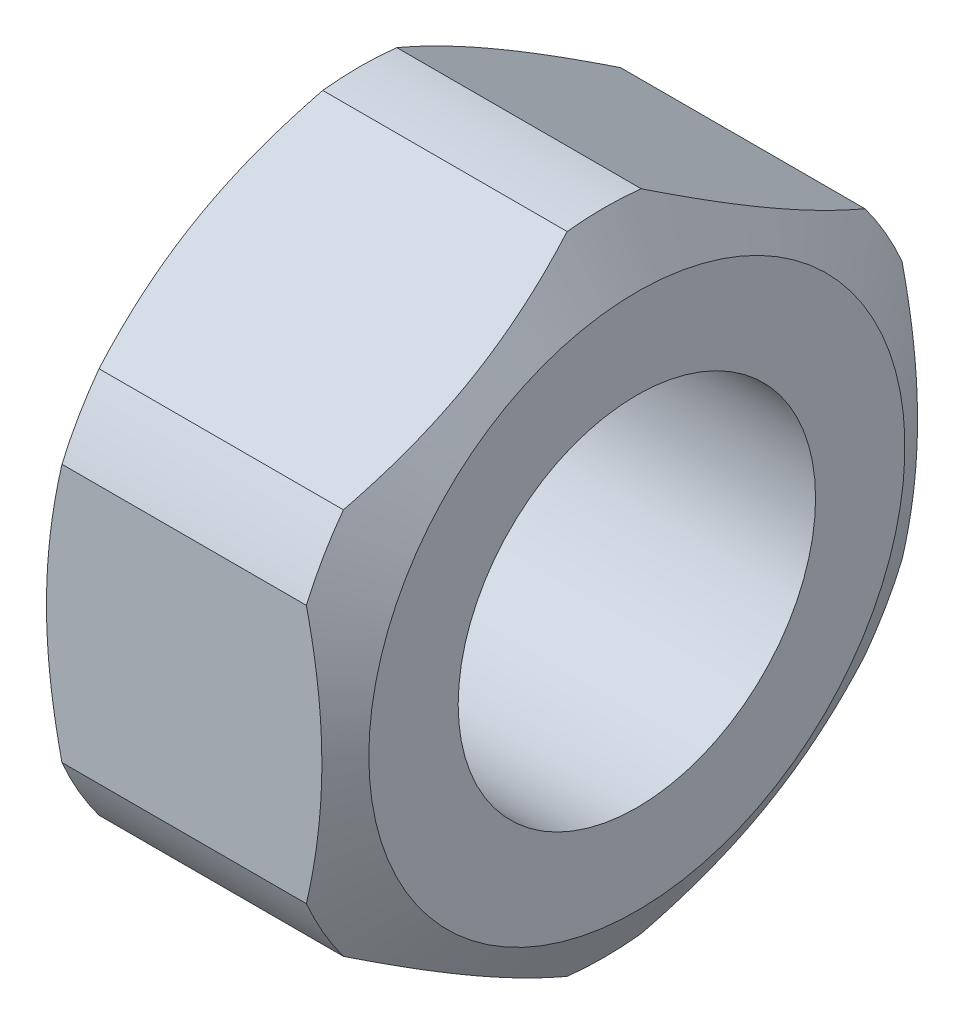
from build123d import *

# Parameters (mm, degrees)
SKETCH_2_OUTSIDE_W  = 16.154
SKETCH_2_OUTSIDE_H  = 16.154
CUT_EXTRUDE_1_DEPTH = 6.2


with BuildPart() as part:
    # Эскиз1 → Повернуть1 (revolve)
    with BuildSketch(Plane.XY):
        Polygon((2.6, 3), (-2.6, 3), (-2.6, 4.5), (-2.051517244, 5.45), (2.051517244, 5.45), (2.6, 4.5), align=None)
    revolve(axis=Axis((-345.378129483, 0, 0), (1, 0, 0)))

    # Эскиз2 outside → Вырез-Вытянуть1 (cut, through all)
    with BuildSketch(Plane.ZY.offset(2.6)):
        Rectangle(SKETCH_2_OUTSIDE_W, SKETCH_2_OUTSIDE_H)
        Polygon((0, -5.773502692), (5, -2.886751346), (5, 2.886751346), (0, 5.773502692), (-5, 2.886751346), (-5, -2.886751346), align=None, mode=Mode.SUBTRACT)
    extrude(amount=-CUT_EXTRUDE_1_DEPTH, mode=Mode.SUBTRACT)


solid = part.part
